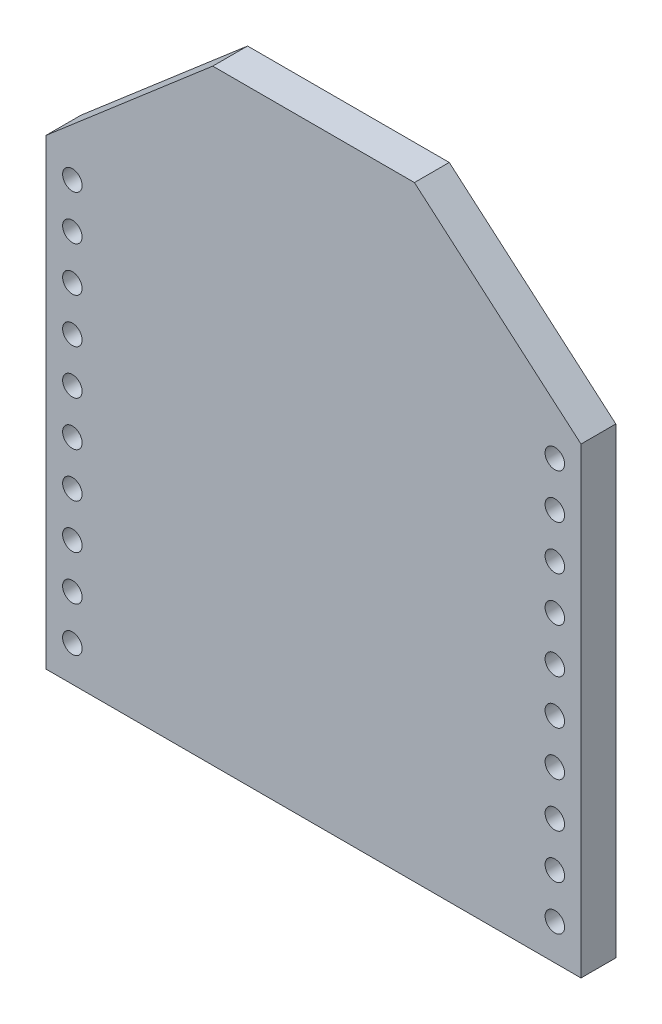
from build123d import *

# Parameters (mm, degrees)
SKETCH1_R           = 0.4445
BOSS_EXTRUDE1_DEPTH = 1.5875


with BuildPart() as part:
    # Sketch1 → Boss-Extrude1 (new body)
    with BuildSketch(Plane.XY):
        Polygon((12.192, 0), (-12.192, 0), (-12.192, 21.082), (-4.5974, 27.6098), (4.5974, 27.6098), (12.192, 21.082), align=None)
        with Locations((-10.9982, 1.628621929)):
            Circle(SKETCH1_R, mode=Mode.SUBTRACT)
        with Locations((-10.9982, 3.660621929)):
            Circle(SKETCH1_R, mode=Mode.SUBTRACT)
        with Locations((-10.9982, 5.692621929)):
            Circle(SKETCH1_R, mode=Mode.SUBTRACT)
        with Locations((-10.9982, 7.724621929)):
            Circle(SKETCH1_R, mode=Mode.SUBTRACT)
        with Locations((-10.9982, 9.756621929)):
            Circle(SKETCH1_R, mode=Mode.SUBTRACT)
        with Locations((-10.9982, 11.788621929)):
            Circle(SKETCH1_R, mode=Mode.SUBTRACT)
        with Locations((-10.9982, 13.820621929)):
            Circle(SKETCH1_R, mode=Mode.SUBTRACT)
        with Locations((-10.9982, 15.852621929)):
            Circle(SKETCH1_R, mode=Mode.SUBTRACT)
        with Locations((-10.9982, 17.884621929)):
            Circle(SKETCH1_R, mode=Mode.SUBTRACT)
        with Locations((-10.9982, 19.916621929)):
            Circle(SKETCH1_R, mode=Mode.SUBTRACT)
        with Locations((10.9982, 19.916621929)):
            Circle(SKETCH1_R, mode=Mode.SUBTRACT)
        with Locations((10.9982, 17.884621929)):
            Circle(SKETCH1_R, mode=Mode.SUBTRACT)
        with Locations((10.9982, 15.852621929)):
            Circle(SKETCH1_R, mode=Mode.SUBTRACT)
        with Locations((10.9982, 13.820621929)):
            Circle(SKETCH1_R, mode=Mode.SUBTRACT)
        with Locations((10.9982, 11.788621929)):
            Circle(SKETCH1_R, mode=Mode.SUBTRACT)
        with Locations((10.9982, 9.756621929)):
            Circle(SKETCH1_R, mode=Mode.SUBTRACT)
        with Locations((10.9982, 7.724621929)):
            Circle(SKETCH1_R, mode=Mode.SUBTRACT)
        with Locations((10.9982, 5.692621929)):
            Circle(SKETCH1_R, mode=Mode.SUBTRACT)
        with Locations((10.9982, 3.660621929)):
            Circle(SKETCH1_R, mode=Mode.SUBTRACT)
        with Locations((10.9982, 1.628621929)):
            Circle(SKETCH1_R, mode=Mode.SUBTRACT)
    extrude(amount=BOSS_EXTRUDE1_DEPTH)


solid = part.part
